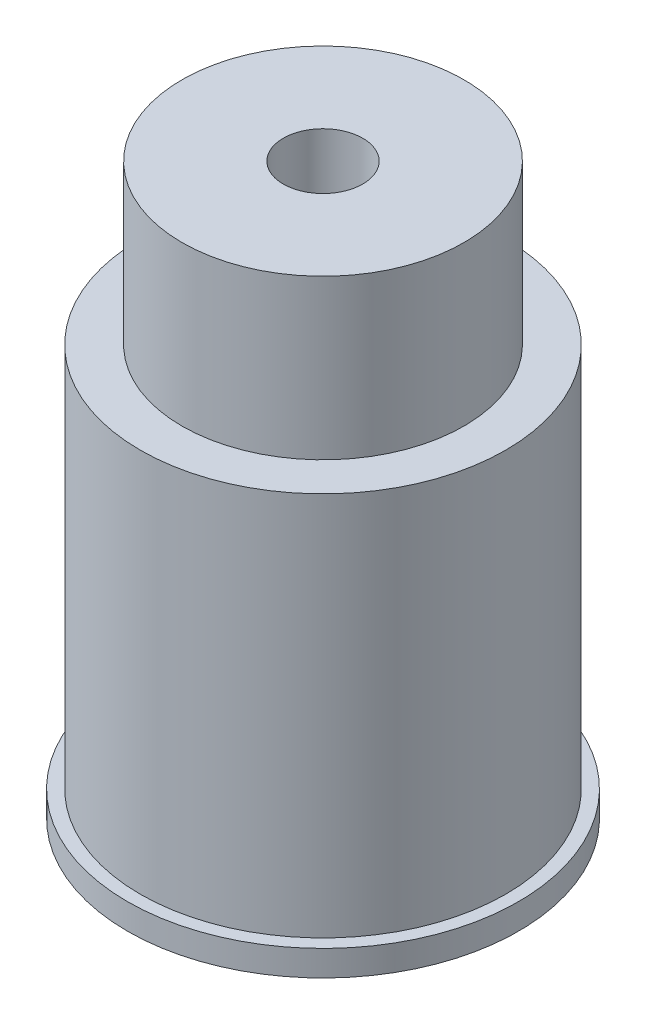
from build123d import *

# Parameters (mm, degrees)
SKETCH2_R           = 7.625
BOSS_EXTRUDE1_DEPTH = 1
SKETCH4_R           = 7.125
BOSS_EXTRUDE2_DEPTH = 15
SKETCH5_R           = 5.5
BOSS_EXTRUDE3_DEPTH = 6.2
SKETCH6_R           = 1.55
CUT_EXTRUDE1_DEPTH  = 23.2


with BuildPart() as part:
    # Sketch2 → Boss-Extrude1 (new body)
    with BuildSketch(Plane(origin=(0, 0, 0), x_dir=(1, 0, 0), z_dir=(0, 1, 0))):
        Circle(SKETCH2_R)
    extrude(amount=BOSS_EXTRUDE1_DEPTH)

    # Sketch4 → Boss-Extrude2 (add)
    with BuildSketch(Plane(origin=(0, 1, 0), x_dir=(1, 0, 0), z_dir=(0, 1, 0))):
        Circle(SKETCH4_R)
    extrude(amount=BOSS_EXTRUDE2_DEPTH)

    # Sketch5 → Boss-Extrude3 (add)
    with BuildSketch(Plane(origin=(0, 16, 0), x_dir=(1, 0, 0), z_dir=(0, 1, 0))):
        Circle(SKETCH5_R)
    extrude(amount=BOSS_EXTRUDE3_DEPTH)

    # Sketch6 → Cut-Extrude1 (cut, through all)
    with BuildSketch(Plane(origin=(0, 22.2, 0), x_dir=(1, 0, 0), z_dir=(0, 1, 0))):
        Circle(SKETCH6_R)
    extrude(amount=-CUT_EXTRUDE1_DEPTH, mode=Mode.SUBTRACT)


solid = part.part
